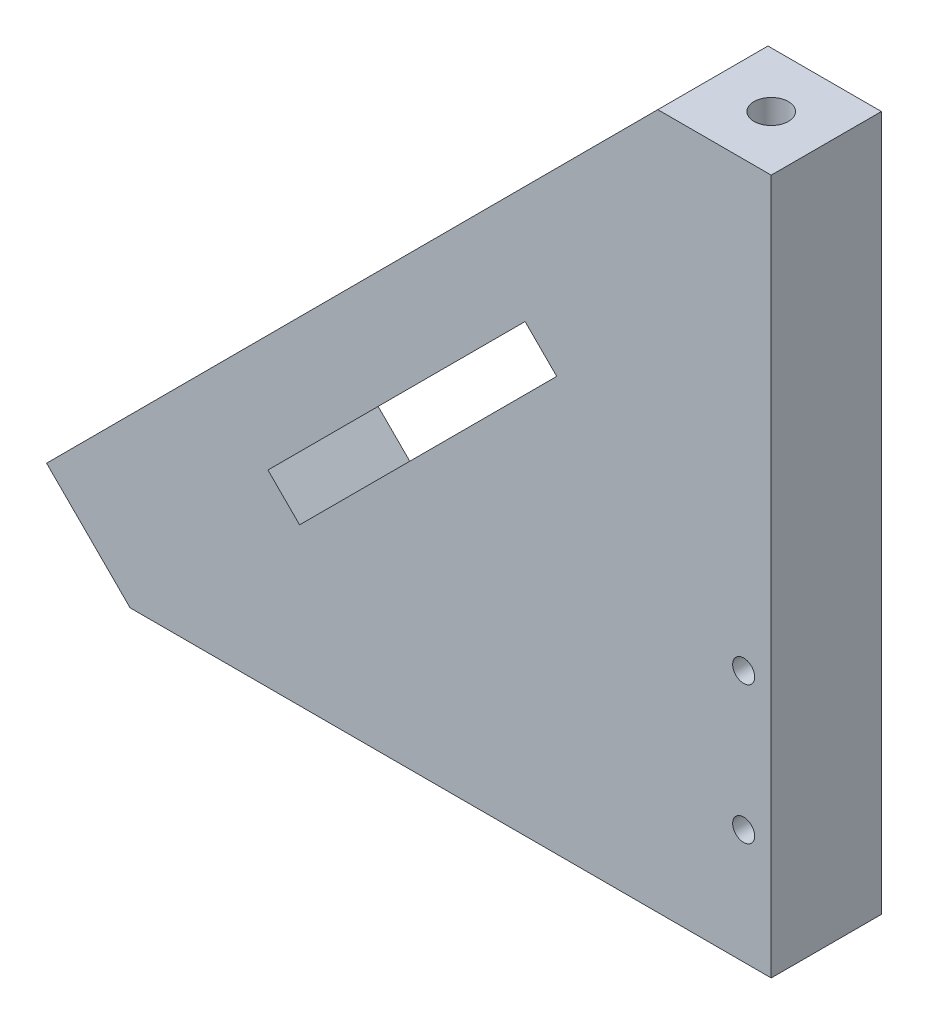
from build123d import *

# Parameters (mm, degrees)
BOSS_EXTRUDE1_DEPTH            = 4
SKETCH3_W                      = 59.68
SKETCH3_H                      = 8
BOSS_EXTRUDE2_DEPTH            = 5.46
CUT_EXTRUDE1_DEPTH             = 9
SKETCH5_W                      = 59.68
SKETCH5_H                      = 2.16
CUT_EXTRUDE2_DEPTH             = 10
CUT_EXTRUDE7_DEPTH             = 10
M2X0_4_TAPPED_HOLE1_D          = 1.6
M2X0_4_TAPPED_HOLE1_DEPTH      = 7
M2X0_4_TAPPED_HOLE1_TIP        = 0.480688495
CBORE_FOR_M3_SHCS2_D           = 3.4
CBORE_FOR_M3_SHCS2_CBORE_D     = 6.5
CBORE_FOR_M3_SHCS2_CBORE_DEPTH = 3
CUT_EXTRUDE10_DEPTH            = 9
SKETCH24_R                     = 1.5
CUT_EXTRUDE12_DEPTH            = 5.5
M3X0_5_TAPPED_HOLE3_D          = 2.5
M3X0_5_TAPPED_HOLE3_DEPTH      = 8.5
M3X0_5_TAPPED_HOLE3_TIP        = 0.751075774
CUT_EXTRUDE13_DEPTH            = 2


with BuildPart() as part:
    # Sketch2 → Boss-Extrude1 (new body, symmetric)
    with BuildSketch(Plane.XY):
        Polygon((-8.360559535, 17.409242356), (51.319440465, 17.409242356), (51.319440465, 71.653558741), (36.009440465, 71.653558741), (43.084036895, 64.586021309), (-1.285963105, 20.171704924), (-8.360559535, 27.239242356), align=None)
    extrude(amount=BOSS_EXTRUDE1_DEPTH, both=True)

    # Sketch3 → Boss-Extrude2 (add)
    with BuildSketch(Plane.XZ.offset(-17.409242356)):
        with Locations((21.479440465, 0)):
            Rectangle(SKETCH3_W, SKETCH3_H)
    extrude(amount=BOSS_EXTRUDE2_DEPTH)

    # Sketch4 → Cut-Extrude1 (cut, through all)
    with BuildSketch(Plane(origin=(0, 0, -4), x_dir=(-1, 0, 0), z_dir=(0, 0, -1))):
        Polygon((-33.450754625, 46.445299472), (-35.748851663, 44.147202433), (-17.08123264, 25.47958341), (-14.783135601, 27.777680449), align=None)
    extrude(amount=-CUT_EXTRUDE1_DEPTH, mode=Mode.SUBTRACT)

    # Sketch5 → Cut-Extrude2 (cut)
    with BuildSketch(Plane(origin=(0, 0, -4), x_dir=(-1, 0, 0), z_dir=(0, 0, -1))):
        with Locations((-21.479440465, 13.029242356)):
            Rectangle(SKETCH5_W, SKETCH5_H)
    extrude(amount=-CUT_EXTRUDE2_DEPTH, mode=Mode.SUBTRACT)

    # Sketch7 → Cut-Extrude7 (cut)
    with BuildSketch(Plane(origin=(0, 0, -4), x_dir=(-1, 0, 0), z_dir=(0, 0, -1))):
        Polygon((1.285963105, 20.171704924), (-5.082290623, 13.803451195), (8.360559535, 13.803451195), (8.360559535, 14.109242356), (8.360559535, 29.043387574), (1.285963105, 29.043387574), align=None)
    extrude(amount=-CUT_EXTRUDE7_DEPTH, mode=Mode.SUBTRACT)

    # M2x0.4 Tapped Hole1
    with Locations(Plane.XY.offset(4)):
        with Locations((49.319440465, 32.429242356), (49.319440465, 22.429242356)):
            Hole(M2X0_4_TAPPED_HOLE1_D / 2, depth=M2X0_4_TAPPED_HOLE1_DEPTH)
            with Locations((0, 0, -(M2X0_4_TAPPED_HOLE1_DEPTH + M2X0_4_TAPPED_HOLE1_TIP / 2))):  # 118° drill point
                Cone(0, M2X0_4_TAPPED_HOLE1_D / 2, M2X0_4_TAPPED_HOLE1_TIP, mode=Mode.SUBTRACT)

    # CBORE for M3 SHCS2 (through all)
    with Locations(Plane(origin=(0, 14.109242356, 0), x_dir=(-1, 0, 0), z_dir=(0, -1, 0))):
        with Locations((-8.776499462, 0)):
            CounterBoreHole(CBORE_FOR_M3_SHCS2_D / 2, CBORE_FOR_M3_SHCS2_CBORE_D / 2, CBORE_FOR_M3_SHCS2_CBORE_DEPTH)

    # Sketch22 → Cut-Extrude10 (cut, through all)
    with BuildSketch(Plane(origin=(0, 0, -4), x_dir=(-1, 0, 0), z_dir=(0, 0, -1))):
        Polygon((-43.084036895, 64.586021309), (-51.319440465, 64.586021309), (-51.319440465, 71.653558741), (-36.009440465, 71.653558741), align=None)
    extrude(amount=-CUT_EXTRUDE10_DEPTH, mode=Mode.SUBTRACT)

    # Sketch24 → Cut-Extrude12 (cut)
    with BuildSketch(Plane(origin=(-10.729470873, 10.71876506, 0), x_dir=(0, 0, 1), z_dir=(-0.707459643, 0.706753743, 0))):
        with Locations((0, 66.141807925)):
            Circle(SKETCH24_R)
    extrude(amount=-CUT_EXTRUDE12_DEPTH, mode=Mode.SUBTRACT)

    # M3x0.5 Tapped Hole3
    with Locations(Plane(origin=(0, 64.586021309, 0), x_dir=(1, 0, 0), z_dir=(0, 1, 0))):
        with Locations((47.319440465, 0)):
            Hole(M3X0_5_TAPPED_HOLE3_D / 2, depth=M3X0_5_TAPPED_HOLE3_DEPTH)
            with Locations((0, 0, -(M3X0_5_TAPPED_HOLE3_DEPTH + M3X0_5_TAPPED_HOLE3_TIP / 2))):  # 118° drill point
                Cone(0, M3X0_5_TAPPED_HOLE3_D / 2, M3X0_5_TAPPED_HOLE3_TIP, mode=Mode.SUBTRACT)

    # Sketch28 → Cut-Extrude13 (cut)
    with BuildSketch(Plane(origin=(0, 0, -4), x_dir=(-1, 0, 0), z_dir=(0, 0, -1))):
        Polygon((-33.450754625, 46.445299472), (-35.748851663, 44.147202433), (-40.345045741, 39.551008355), (-21.677426718, 20.883389332), (-17.08123264, 25.47958341), (-14.783135601, 27.777680449), (-10.545665345, 32.015150705), (-29.20396649, 50.692087606), align=None)
    extrude(amount=-CUT_EXTRUDE13_DEPTH, mode=Mode.SUBTRACT)


solid = part.part
